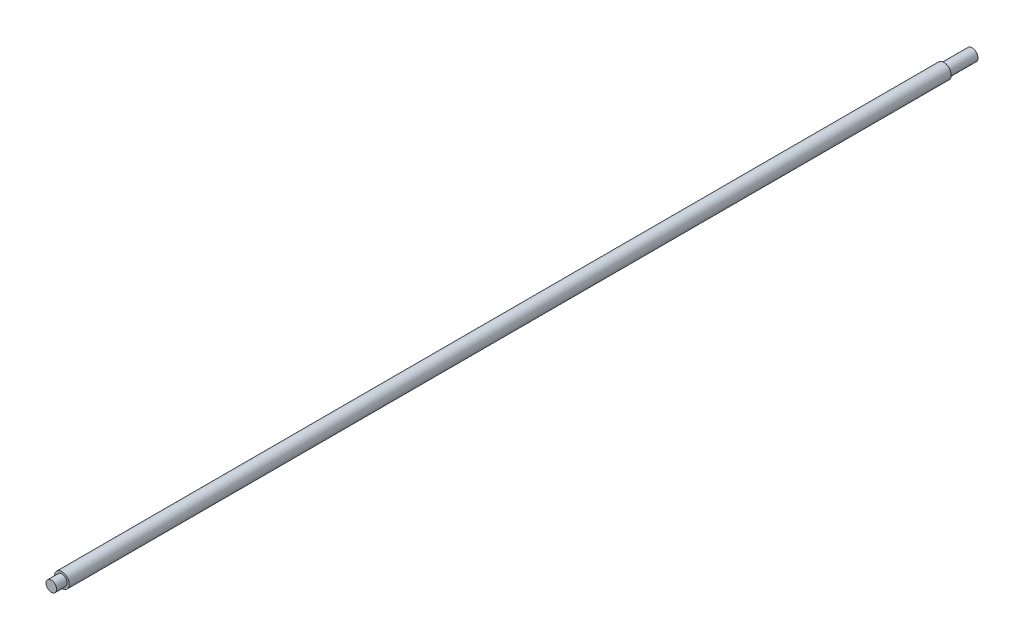
from build123d import *

# Parameters (mm, degrees)
SZKIC2_R                    = 12.5
DODANIE_WYCI_GNI_CIE1_DEPTH = 1497
SZKIC3_R                    = 9
DODANIE_WYCI_GNI_CIE2_DEPTH = 18
SZKIC4_R                    = 10
DODANIE_WYCI_GNI_CIE3_DEPTH = 48


with BuildPart() as part:
    # Szkic2 → Dodanie-wyciągnięcie1 (new body)
    with BuildSketch(Plane.XY):
        Circle(SZKIC2_R)
    extrude(amount=DODANIE_WYCI_GNI_CIE1_DEPTH)

    # Szkic3 → Dodanie-wyciągnięcie2 (add)
    with BuildSketch(Plane.XY.offset(1497)):
        Circle(SZKIC3_R)
    extrude(amount=DODANIE_WYCI_GNI_CIE2_DEPTH)

    # Szkic4 → Dodanie-wyciągnięcie3 (add)
    with BuildSketch(Plane(origin=(0, 0, 0), x_dir=(-1, 0, 0), z_dir=(0, 0, -1))):
        Circle(SZKIC4_R)
    extrude(amount=DODANIE_WYCI_GNI_CIE3_DEPTH)


solid = part.part
